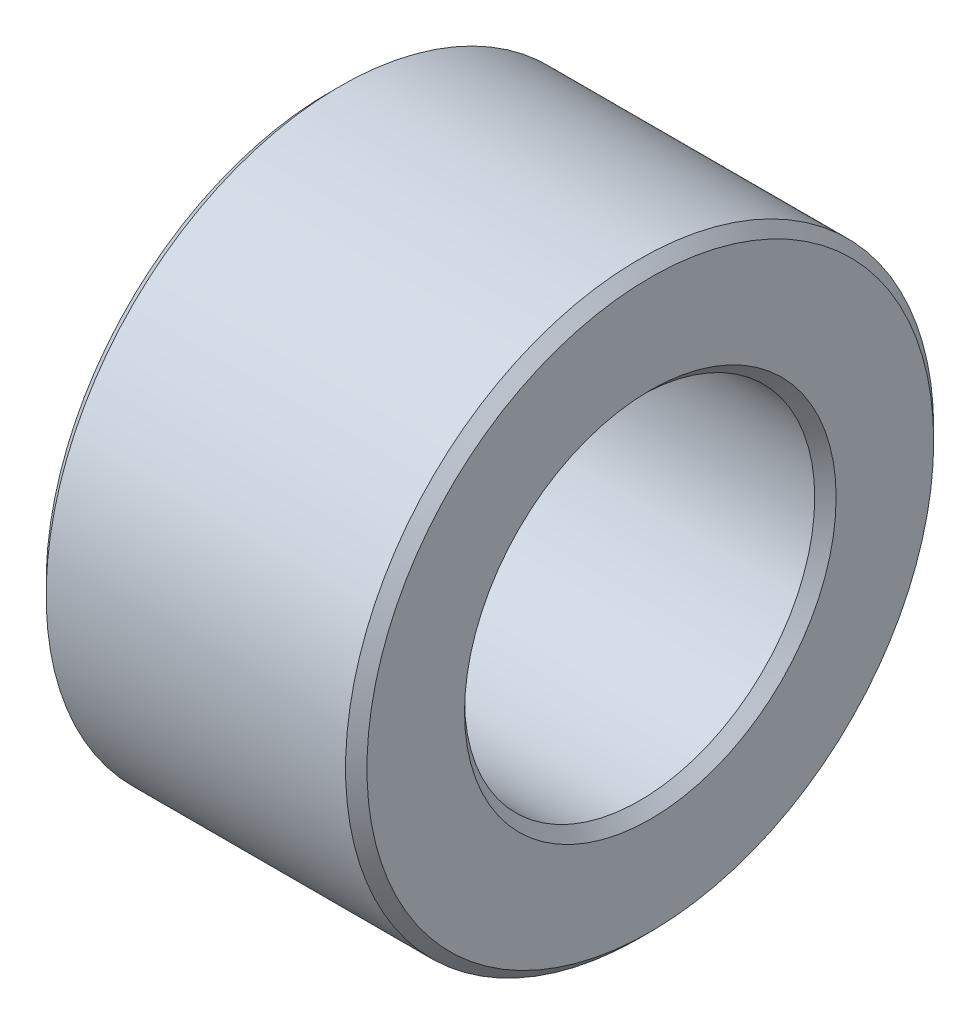
from build123d import *

# Parameters (mm, degrees)
SKETCH1_R          = 55
SKETCH1_R_2        = 30
EXTRUDE1_DEPTH     = 30
SKETCH2_R          = 32.75
MACHINE_DEPTH      = 30
CHAMFER_OUTER_SIZE = 2
CHAMFER_INNER_SIZE = 2


with BuildPart() as part:
    # Sketch1 → Extrude1 (new body, symmetric)
    with BuildSketch(Plane(origin=(0, 0, 0), x_dir=(0, 0, -1), z_dir=(1, 0, 0))):
        Circle(SKETCH1_R)
        Circle(SKETCH1_R_2, mode=Mode.SUBTRACT)
    extrude(amount=EXTRUDE1_DEPTH, both=True)

    # Sketch2 → Machine (cut, symmetric)
    with BuildSketch(Plane(origin=(0, 0, 0), x_dir=(0, 0, -1), z_dir=(1, 0, 0))):
        Circle(SKETCH2_R)
    extrude(amount=MACHINE_DEPTH, both=True, mode=Mode.SUBTRACT)

    # Chamfer-Outer
    chamfer_outer_edges = [part.edges().sort_by_distance(p)[0] for p in [
        (30, 0, 55),
        (-30, 0, 55),
    ]]
    chamfer(chamfer_outer_edges, length=CHAMFER_OUTER_SIZE)

    # Chamfer-Inner
    chamfer_inner_edges = [part.edges().sort_by_distance(p)[0] for p in [
        (30, 0, 32.75),
        (-30, 0, 32.75),
    ]]
    chamfer(chamfer_inner_edges, length=CHAMFER_INNER_SIZE)


solid = part.part
